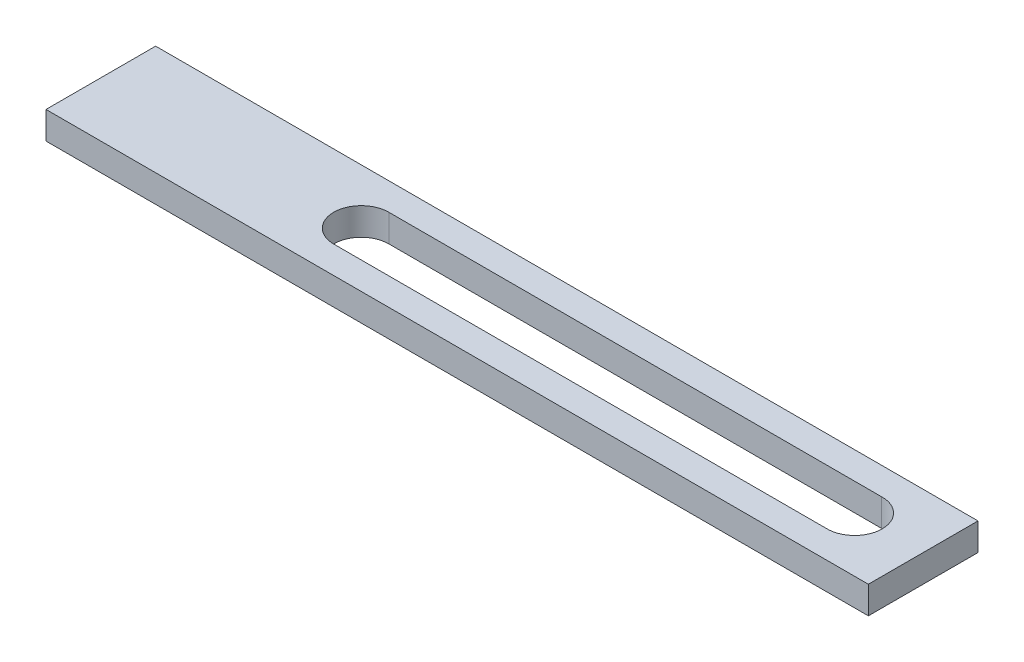
from build123d import *

# Parameters (mm, degrees)
SKETCH_1_W          = 300
SKETCH_1_H          = 40
EXTRUDE_1_DEPTH     = 10
CUT_EXTRUDE_1_REACH = 12


with BuildPart() as part:
    # Эскиз1 → Бобышка-Вытянуть1 (new body)
    with BuildSketch(Plane(origin=(0, 0, 0), x_dir=(1, 0, 0), z_dir=(0, 1, 0))):
        with Locations((150, 20)):
            Rectangle(SKETCH_1_W, SKETCH_1_H)
    extrude(amount=EXTRUDE_1_DEPTH)

    # Эскиз2 → Вырез-Вытянуть1 (cut, up to next)
    with BuildSketch(Plane(origin=(0, 10, 0), x_dir=(1, 0, 0), z_dir=(0, 1, 0)), mode=Mode.PRIVATE) as cut_extrude_1_sk1:
        with BuildLine():
            Line((95, 9.95), (274.721446052, 9.953861055))
            ThreePointArc((274.721446052, 9.953861055), (285.05, 20), (274.721446052, 30.046138945))
            Line((274.721446052, 30.046138945), (95, 30.05))
            ThreePointArc((95, 30.05), (84.95, 20), (95, 9.95))
        make_face()
    cut_extrude_1_tool1 = extrude(cut_extrude_1_sk1.sketch, amount=-CUT_EXTRUDE_1_REACH, mode=Mode.PRIVATE) & part.part
    add(cut_extrude_1_tool1.solids().sort_by_distance((184.994726, 10, -20))[0], mode=Mode.SUBTRACT)


solid = part.part
